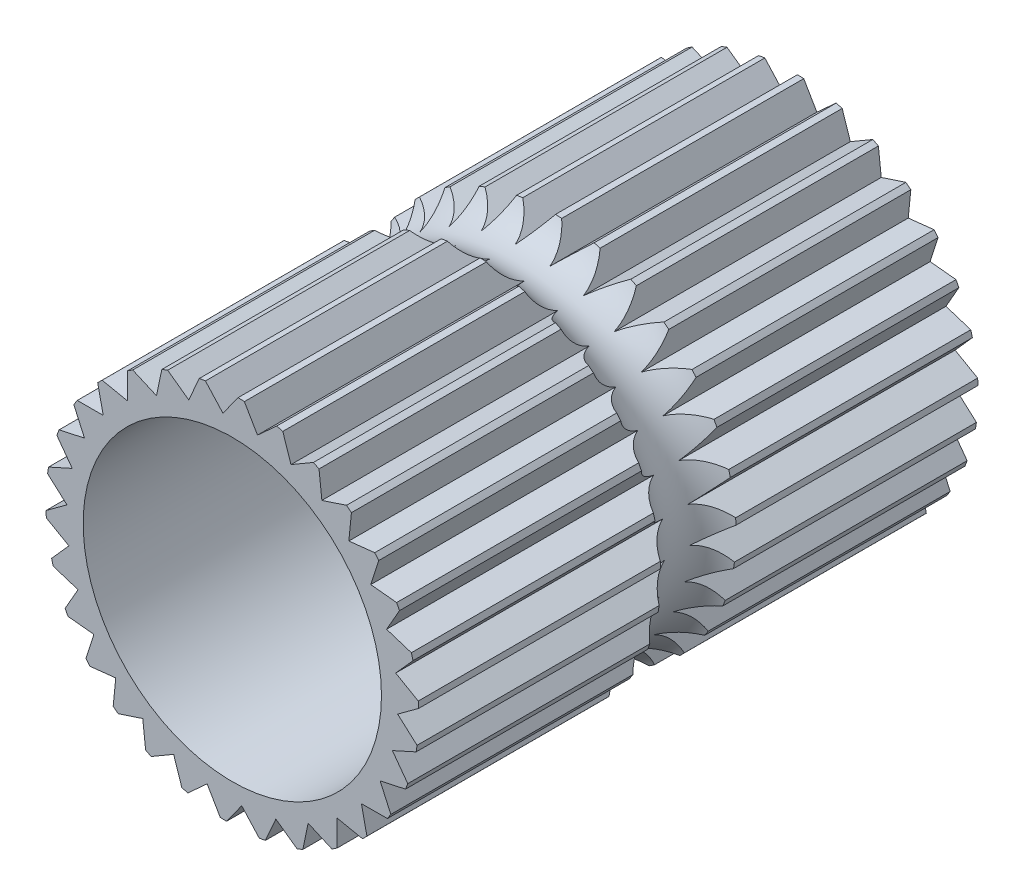
from build123d import *

# Parameters (mm, degrees)
SKETCH1_R           = 2.5
SKETCH1_R_2         = 2
BOSS_EXTRUDE1_DEPTH = 7.5
SKETCH2_R           = 0.275529745
SKETCH7_R           = 0.569845932
CUT_EXTRUDE2_DEPTH  = 10


with BuildPart() as part:
    # Sketch1 → Boss-Extrude1 (new body)
    with BuildSketch(Plane.XY):
        Circle(SKETCH1_R)
        Circle(SKETCH1_R_2, mode=Mode.SUBTRACT)
    extrude(amount=BOSS_EXTRUDE1_DEPTH)

    # Cut-Sweep1: sweep along a path in Sketch4
    with BuildLine(Plane.XY.offset(3.75)) as cut_sweep1_path:
        Line((0, 0), (0, -0.245184027))
        ThreePointArc((0, -0.245184027), (0.585786438, -1.65939759), (2, -2.245184027))
        Line((2, -2.245184027), (3.119091287, -2.245184027))
    # Sketch2 → Cut-Sweep1 (sweep, cut)
    with BuildSketch(Plane(origin=(0, 0, 0), x_dir=(1, 0, 0), z_dir=(0, 1, 0))):
        with Locations((-0.110733435, -3.75)):
            Circle(SKETCH2_R)
    sweep(path=cut_sweep1_path.line, mode=Mode.SUBTRACT)

    # Cut-Sweep2: sweep along a path in Sketch6
    with BuildLine(Plane.XY.offset(3.75)) as cut_sweep2_path:
        CenterArc((0, 0), 2.5, 0, 360)
    # Sketch7 → Cut-Sweep2 (sweep, cut)
    with BuildSketch(Plane(origin=(0, 0, 0), x_dir=(1, 0, 0), z_dir=(0, 1, 0))):
        with Locations((2.763697925, -3.75)):
            Circle(SKETCH7_R)
    sweep(path=cut_sweep2_path.line, mode=Mode.SUBTRACT)

    # Sketch8 → Cut-Extrude2 (cut)
    with BuildSketch(Plane.XY.offset(7.5)):
        with BuildLine():
            Line((2.422661306, 0.617018799), (2.190596666, 0.356815832))
            Line((2.190596666, 0.356815832), (2.493241059, 0.183709067))
            ThreePointArc((2.493241059, 0.183709067), (2.467481174, 0.401916228), (2.422661306, 0.617018799))
        make_face()
        with BuildLine():
            Line((2.216913056, -0.106432107), (2.476953023, -0.338679381))
            ThreePointArc((2.476953023, -0.338679381), (2.497123873, -0.119884789), (2.498005765, 0.09983585))
            Line((2.498005765, 0.09983585), (2.216913056, -0.106432107))
        make_face()
        with BuildLine():
            Line((2.146339708, -0.565028452), (2.352410253, -0.846265915))
            ThreePointArc((2.352410253, -0.846265915), (2.417630276, -0.636446265), (2.464175386, -0.421710405))
            Line((2.464175386, -0.421710405), (2.146339708, -0.565028452))
        make_face()
        with BuildLine():
            Line((1.981961015, -0.998930342), (2.125055868, -1.316866568))
            ThreePointArc((2.125055868, -1.316866568), (2.232474635, -1.125191986), (2.322648718, -0.924825892))
            Line((2.322648718, -0.924825892), (1.981961015, -0.998930342))
        make_face()
        with BuildLine():
            Line((1.730961115, -1.389174183), (1.804826344, -1.729913833))
            ThreePointArc((1.804826344, -1.729913833), (1.949749139, -1.564761417), (2.079611156, -1.38752205))
            Line((2.079611156, -1.38752205), (1.730961115, -1.389174183))
        make_face()
        with BuildLine():
            Line((1.404309908, -1.718704446), (1.405717248, -2.067355562))
            ThreePointArc((1.405717248, -2.067355562), (1.581810251, -1.935943266), (1.745684607, -1.789576836))
            Line((1.745684607, -1.789576836), (1.404309908, -1.718704446))
        make_face()
        with BuildLine():
            Line((1.01628362, -1.973119078), (0.945171563, -2.314443932))
            ThreePointArc((0.945171563, -2.314443932), (1.144738664, -2.222515105), (1.335463265, -2.113418527))
            Line((1.335463265, -2.113418527), (1.01628362, -1.973119078))
        make_face()
        with BuildLine():
            Line((0.583840861, -2.141298938), (0.443317346, -2.460379997))
            ThreePointArc((0.443317346, -2.460379997), (0.657636504, -2.411952369), (0.866875769, -2.344893687))
            Line((0.866875769, -2.344893687), (0.583840861, -2.141298938))
        make_face()
        with BuildLine():
            Line((0.125881455, -2.215893759), (-0.077911967, -2.49878565))
            ThreePointArc((-0.077911967, -2.49878565), (0.141792473, -2.49597574), (0.360401642, -2.47388574))
            Line((0.360401642, -2.47388574), (0.125881455, -2.215893759))
        make_face()
        with BuildLine():
            Line((-0.337579575, -2.19364339), (-0.595736153, -2.42798238))
            ThreePointArc((-0.595736153, -2.42798238), (-0.380248569, -2.470912994), (-0.161823765, -2.494757116))
            Line((-0.161823765, -2.494757116), (-0.337579575, -2.19364339))
        make_face()
        with BuildLine():
            Line((-0.786286758, -2.075520278), (-1.087523811, -2.251064628))
            ThreePointArc((-1.087523811, -2.251064628), (-0.885670924, -2.337859494), (-0.676976698, -2.406595635))
            Line((-0.676976698, -2.406595635), (-0.786286758, -2.075520278))
        make_face()
        with BuildLine():
            Line((-1.200629436, -1.866686971), (-1.531781459, -1.975764551))
            ThreePointArc((-1.531781459, -1.975764551), (-1.352385209, -2.102630316), (-1.162542501, -2.213254376))
            Line((-1.162542501, -2.213254376), (-1.200629436, -1.866686971))
        make_face()
        with BuildLine():
            Line((-1.562498847, -1.576270486), (-1.909092908, -1.614114082))
            ThreePointArc((-1.909092908, -1.614114082), (-1.759993772, -1.775506103), (-1.597299617, -1.923183281))
            Line((-1.597299617, -1.923183281), (-1.562498847, -1.576270486))
        make_face()
        with BuildLine():
            Line((-1.85607956, -1.216963417), (-2.202967835, -1.181919082))
            ThreePointArc((-2.202967835, -1.181919082), (-2.090682161, -1.370783754), (-1.962247076, -1.549059848))
            Line((-1.962247076, -1.549059848), (-1.85607956, -1.216963417))
        make_face()
        with BuildLine():
            Line((-2.06854069, -0.804469207), (-2.400562497, -0.698068547))
            ThreePointArc((-2.400562497, -0.698068547), (-2.329997708, -0.906151577), (-2.241434922, -1.107235066))
            Line((-2.241434922, -1.107235066), (-2.06854069, -0.804469207))
        make_face()
        with BuildLine():
            Line((-2.190596666, -0.356815832), (-2.493241059, -0.183709067))
            ThreePointArc((-2.493241059, -0.183709067), (-2.467481174, -0.401916228), (-2.422661306, -0.617018799))
            Line((-2.422661306, -0.617018799), (-2.190596666, -0.356815832))
        make_face()
        with BuildLine():
            Line((-2.216913056, 0.106432107), (-2.476953023, 0.338679381))
            ThreePointArc((-2.476953023, 0.338679381), (-2.497123873, 0.119884789), (-2.498005765, -0.09983585))
            Line((-2.498005765, -0.09983585), (-2.216913056, 0.106432107))
        make_face()
        with BuildLine():
            Line((-2.146339708, 0.565028452), (-2.352410253, 0.846265915))
            ThreePointArc((-2.352410253, 0.846265915), (-2.417630276, 0.636446265), (-2.464175386, 0.421710405))
            Line((-2.464175386, 0.421710405), (-2.146339708, 0.565028452))
        make_face()
        with BuildLine():
            Line((-1.981961015, 0.998930342), (-2.125055868, 1.316866568))
            ThreePointArc((-2.125055868, 1.316866568), (-2.232474635, 1.125191986), (-2.322648718, 0.924825892))
            Line((-2.322648718, 0.924825892), (-1.981961015, 0.998930342))
        make_face()
        with BuildLine():
            Line((-1.730961115, 1.389174183), (-1.804826344, 1.729913833))
            ThreePointArc((-1.804826344, 1.729913833), (-1.949749139, 1.564761417), (-2.079611156, 1.38752205))
            Line((-2.079611156, 1.38752205), (-1.730961115, 1.389174183))
        make_face()
        with BuildLine():
            Line((-1.404309908, 1.718704446), (-1.405717248, 2.067355562))
            ThreePointArc((-1.405717248, 2.067355562), (-1.581810251, 1.935943266), (-1.745684607, 1.789576836))
            Line((-1.745684607, 1.789576836), (-1.404309908, 1.718704446))
        make_face()
        with BuildLine():
            Line((-1.01628362, 1.973119078), (-0.945171563, 2.314443932))
            ThreePointArc((-0.945171563, 2.314443932), (-1.144738664, 2.222515105), (-1.335463265, 2.113418527))
            Line((-1.335463265, 2.113418527), (-1.01628362, 1.973119078))
        make_face()
        with BuildLine():
            Line((-0.583840861, 2.141298938), (-0.443317346, 2.460379997))
            ThreePointArc((-0.443317346, 2.460379997), (-0.657636504, 2.411952369), (-0.866875769, 2.344893687))
            Line((-0.866875769, 2.344893687), (-0.583840861, 2.141298938))
        make_face()
        with BuildLine():
            Line((-0.125881455, 2.215893759), (0.077911967, 2.49878565))
            ThreePointArc((0.077911967, 2.49878565), (-0.141792473, 2.49597574), (-0.360401642, 2.47388574))
            Line((-0.360401642, 2.47388574), (-0.125881455, 2.215893759))
        make_face()
        with BuildLine():
            Line((0.337579575, 2.19364339), (0.595736153, 2.42798238))
            ThreePointArc((0.595736153, 2.42798238), (0.380248569, 2.470912994), (0.161823765, 2.494757116))
            Line((0.161823765, 2.494757116), (0.337579575, 2.19364339))
        make_face()
        with BuildLine():
            Line((0.786286758, 2.075520278), (1.087523811, 2.251064628))
            ThreePointArc((1.087523811, 2.251064628), (0.885670924, 2.337859494), (0.676976698, 2.406595635))
            Line((0.676976698, 2.406595635), (0.786286758, 2.075520278))
        make_face()
        with BuildLine():
            Line((1.200629436, 1.866686971), (1.531781459, 1.975764551))
            ThreePointArc((1.531781459, 1.975764551), (1.352385209, 2.102630316), (1.162542501, 2.213254376))
            Line((1.162542501, 2.213254376), (1.200629436, 1.866686971))
        make_face()
        with BuildLine():
            Line((1.562498847, 1.576270486), (1.909092908, 1.614114082))
            ThreePointArc((1.909092908, 1.614114082), (1.759993772, 1.775506103), (1.597299617, 1.923183281))
            Line((1.597299617, 1.923183281), (1.562498847, 1.576270486))
        make_face()
        with BuildLine():
            Line((1.85607956, 1.216963417), (2.202967835, 1.181919082))
            ThreePointArc((2.202967835, 1.181919082), (2.090682161, 1.370783754), (1.962247076, 1.549059848))
            Line((1.962247076, 1.549059848), (1.85607956, 1.216963417))
        make_face()
        with BuildLine():
            Line((2.06854069, 0.804469207), (2.400562497, 0.698068547))
            ThreePointArc((2.400562497, 0.698068547), (2.329997708, 0.906151577), (2.241434922, 1.107235066))
            Line((2.241434922, 1.107235066), (2.06854069, 0.804469207))
        make_face()
    extrude(amount=-CUT_EXTRUDE2_DEPTH, mode=Mode.SUBTRACT)


solid = part.part
